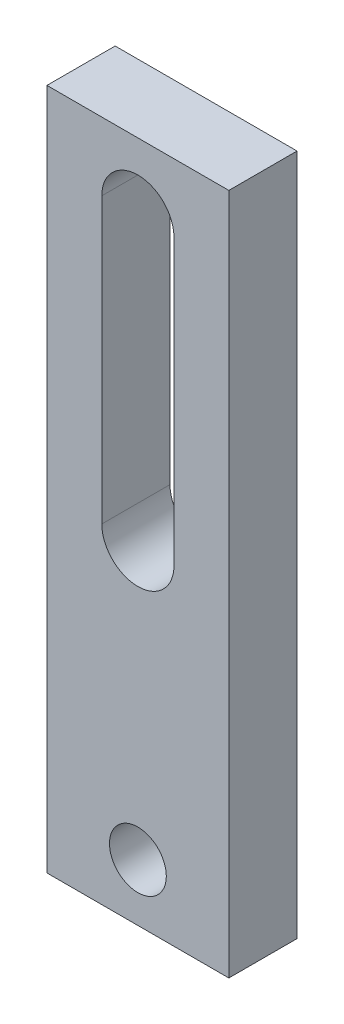
from build123d import *

# Parameters (mm, degrees)
SKETCH1_W           = 8
SKETCH1_H           = 30
BOSS_EXTRUDE1_DEPTH = 3
SKETCH2_R           = 1.25
CUT_EXTRUDE1_DEPTH  = 3


with BuildPart() as part:
    # Sketch1 → Boss-Extrude1 (new body)
    with BuildSketch(Plane.XY):
        with Locations((-18.117004067, 15)):
            Rectangle(SKETCH1_W, SKETCH1_H)
    extrude(amount=BOSS_EXTRUDE1_DEPTH)

    # Sketch2 → Cut-Extrude1 (cut)
    with BuildSketch(Plane.XY.offset(3)):
        with Locations((-18.117004067, 2.5)):
            Circle(SKETCH2_R)
        with BuildLine():
            Line((-16.529504067, 27), (-16.529504067, 14.5))
            ThreePointArc((-16.529504067, 14.5), (-18.117004067, 12.9125), (-19.704504067, 14.5))
            Line((-19.704504067, 14.5), (-19.704504067, 27))
            ThreePointArc((-19.704504067, 27), (-18.117004067, 28.5875), (-16.529504067, 27))
        make_face()
    extrude(amount=-CUT_EXTRUDE1_DEPTH, mode=Mode.SUBTRACT)


solid = part.part
